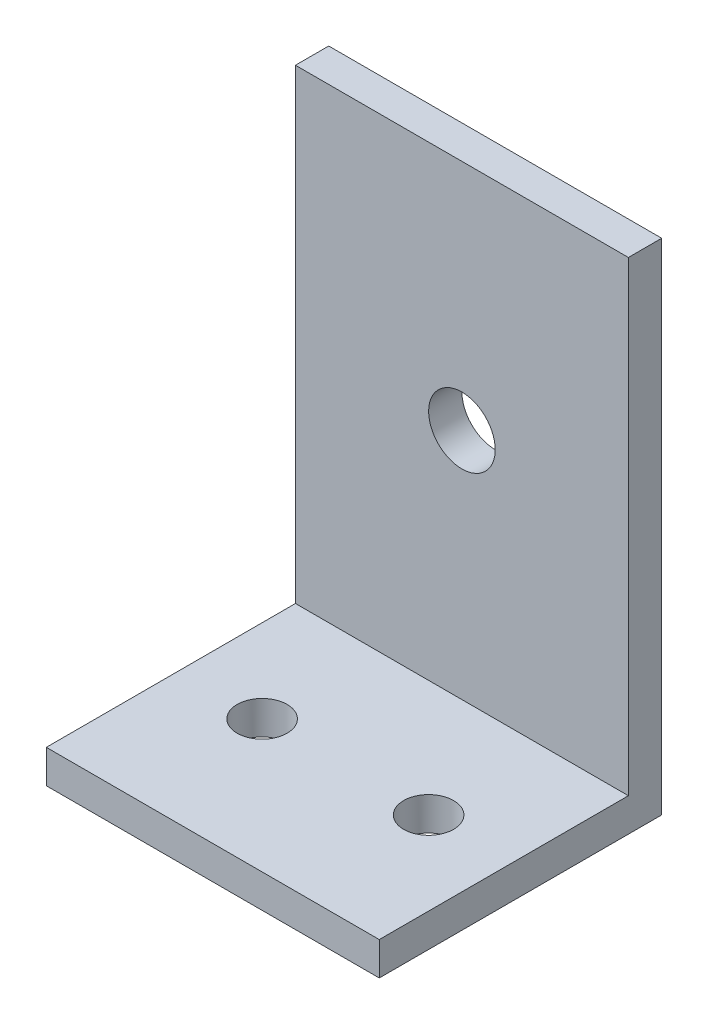
from build123d import *

# Parameters (mm, degrees)
EXTRUDE_1_DEPTH      = 30
SKETCH_6_W           = 21.999074129
SKETCH_6_H           = 43.978081363
CUT_EXTRUDE_5_DEPTH  = 10
SKETCH_7_W           = 30
SKETCH_7_H           = 21.035862509
CUT_EXTRUDE_6_DEPTH  = 10
SKETCH_8_R           = 1.5
CUT_EXTRUDE_7_DEPTH  = 10
SKETCH_9_W           = 20
SKETCH_9_H           = 13.964137491
CUT_EXTRUDE_8_DEPTH  = 1
SKETCH_10_W          = 20
SKETCH_10_H          = 36
CUT_EXTRUDE_9_DEPTH  = 1
SKETCH_11_W          = 20
SKETCH_11_H          = 2
CUT_EXTRUDE_10_DEPTH = 8
SKETCH_12_R          = 2
CUT_EXTRUDE_11_DEPTH = 8


with BuildPart() as part:
    # 草图1 → 凸台-拉伸1 (new body)
    with BuildSketch(Plane(origin=(0, 0, 0), x_dir=(0, 0, -1), z_dir=(1, 0, 0))):
        Polygon((0, 0), (0, 35), (3, 35), (3, -3), (-35, -3), (-35, 0), align=None)
    extrude(amount=EXTRUDE_1_DEPTH)

    # 草图6 → 切除-拉伸5 (cut)
    with BuildSketch(Plane.ZY):
        with Locations((2.964600426, 15.968723176)):
            Rectangle(SKETCH_6_W, SKETCH_6_H)
    extrude(amount=-CUT_EXTRUDE_5_DEPTH, mode=Mode.SUBTRACT)

    # 草图7 → 切除-拉伸6 (cut)
    with BuildSketch(Plane(origin=(0, 0, 0), x_dir=(1, 0, 0), z_dir=(0, 1, 0))):
        with Locations((15, -24.482068746)):
            Rectangle(SKETCH_7_W, SKETCH_7_H)
    extrude(amount=-CUT_EXTRUDE_6_DEPTH, mode=Mode.SUBTRACT)

    # 草图8 → 切除-拉伸7 (cut)
    with BuildSketch(Plane(origin=(0, 0, 0), x_dir=(1, 0, 0), z_dir=(0, 1, 0))):
        with Locations((15, -6)):
            Circle(SKETCH_8_R)
        with Locations((25, -6)):
            Circle(SKETCH_8_R)
    extrude(amount=-CUT_EXTRUDE_7_DEPTH, mode=Mode.SUBTRACT)

    # 草图9 → 切除-拉伸8 (cut)
    with BuildSketch(Plane(origin=(0, 0, 0), x_dir=(1, 0, 0), z_dir=(0, 1, 0))):
        with Locations((20, -6.982068746)):
            Rectangle(SKETCH_9_W, SKETCH_9_H)
    extrude(amount=-CUT_EXTRUDE_8_DEPTH, mode=Mode.SUBTRACT)

    # 草图10 → 切除-拉伸9 (cut)
    with BuildSketch(Plane.XY):
        with Locations((20, 17)):
            Rectangle(SKETCH_10_W, SKETCH_10_H)
    extrude(amount=-CUT_EXTRUDE_9_DEPTH, mode=Mode.SUBTRACT)

    # 草图11 → 切除-拉伸10 (cut)
    with BuildSketch(Plane(origin=(0, 35, 0), x_dir=(1, 0, 0), z_dir=(0, 1, 0))):
        with Locations((20, 2)):
            Rectangle(SKETCH_11_W, SKETCH_11_H)
    extrude(amount=-CUT_EXTRUDE_10_DEPTH, mode=Mode.SUBTRACT)

    # 草图12 → 切除-拉伸11 (cut)
    with BuildSketch(Plane(origin=(0, 0, -3), x_dir=(-1, 0, 0), z_dir=(0, 0, -1))):
        with Locations((-20, 13)):
            Circle(SKETCH_12_R)
    extrude(amount=-CUT_EXTRUDE_11_DEPTH, mode=Mode.SUBTRACT)


solid = part.part
